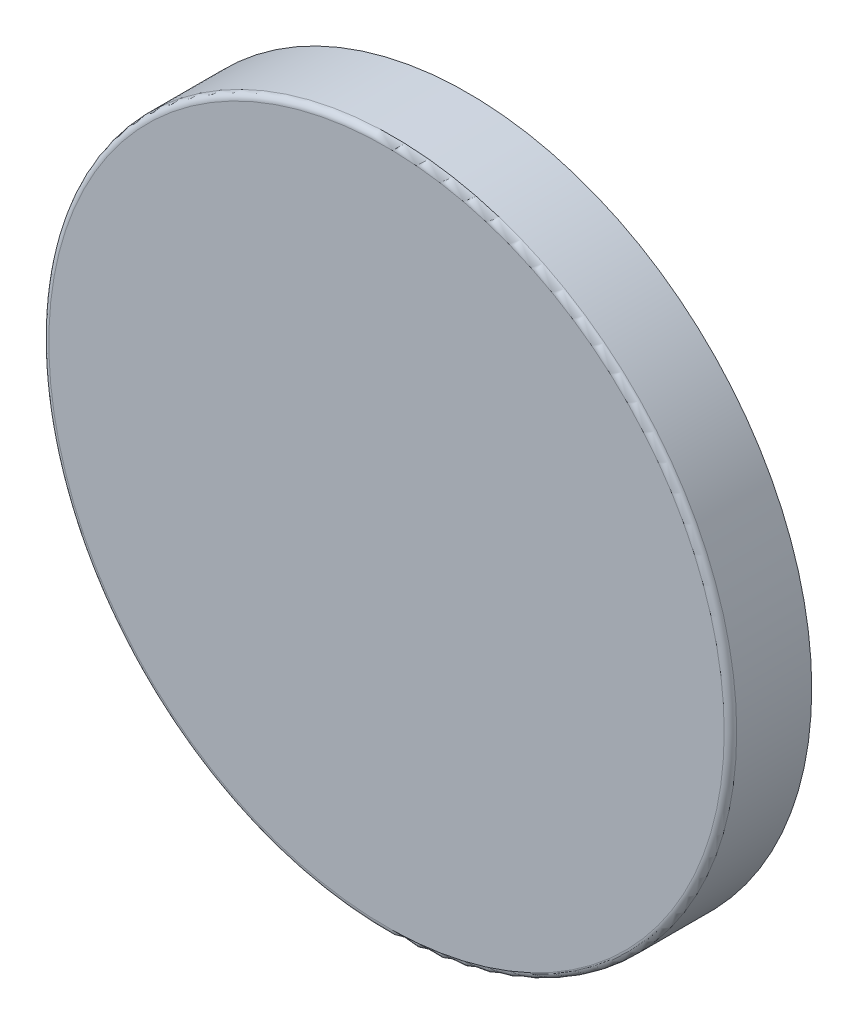
from build123d import *

# Parameters (mm, degrees)
SKETCH1_R           = 55
BOSS_EXTRUDE1_DEPTH = 13
FILLET1_R           = 1


with BuildPart() as part:
    # Sketch1 → Boss-Extrude1 (new body)
    with BuildSketch(Plane.XY):
        Circle(SKETCH1_R)
    extrude(amount=BOSS_EXTRUDE1_DEPTH)

    # Fillet1
    fillet1_edges = [part.edges().sort_by_distance(p)[0] for p in [
        (-55, 0, 13),
    ]]
    fillet(fillet1_edges, radius=FILLET1_R)


solid = part.part
